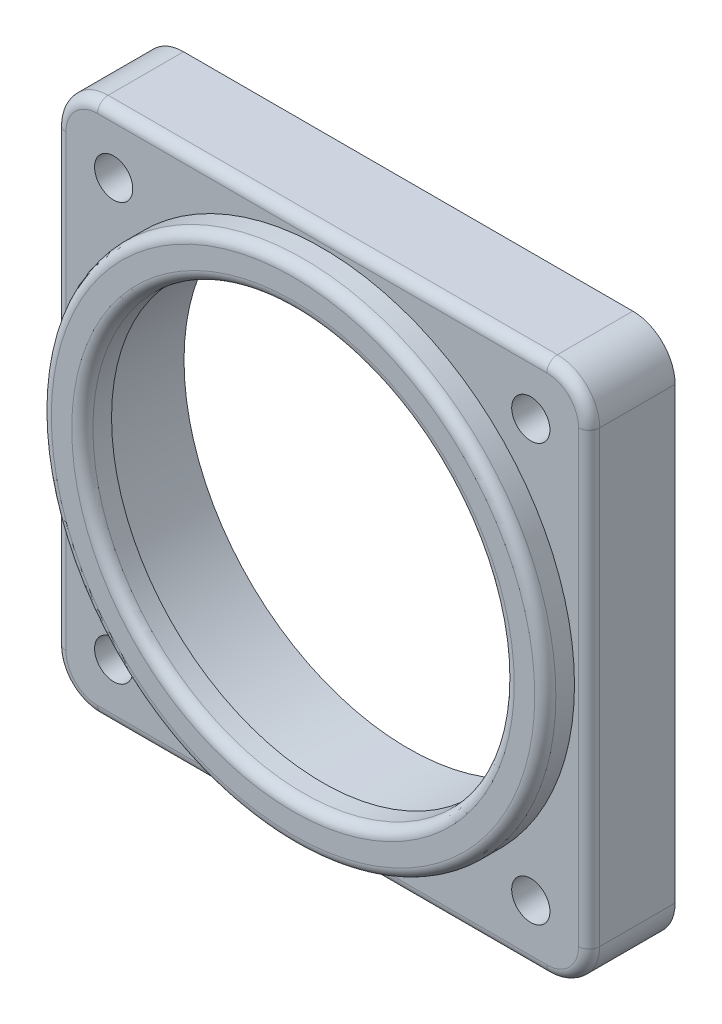
from build123d import *

# Parameters (mm, degrees)
SKETCH1_R               = 2.159
SKETCH1_R_2             = 28.5115
BOSS_EXTRUDE1_DEPTH     = 9.7155
SKETCH1_3_R             = 28.5115
SKETCH1_3_R_2           = 23.8125
EXTENDED_BEZEL_DEPTH    = 13.0175
SKETCH1_5_R             = 28.5115
SKETCH1_5_R_2           = 23.8125
BOSS_EXTRUDE4_DEPTH     = 6.35
SKETCH2_R               = 25.3365
CUT_EXTRUDE1_DEPTH      = 7.35
CUT_EXTRUDE1_DEPTH_BACK = 9.7155
FILLET1_R               = 1.1938
SKETCH3_R               = 28.5115
CUT_EXTRUDE2_DEPTH      = 7.35


with BuildPart() as part:
    # Sketch1 → Boss-Extrude1 (new body)
    with BuildSketch(Plane.XY):
        with BuildLine():
            ThreePointArc((-24.49722379, -28.024879905), (-26.788104009, -26.788104009), (-28.024879905, -24.49722379))
            Line((-28.024879905, -24.49722379), (-30.1625, -14.199031657))
            Line((-30.1625, -14.199031657), (-30.1625, 14.199031657))
            Line((-30.1625, 14.199031657), (-28.024879905, 24.49722379))
            ThreePointArc((-28.024879905, 24.49722379), (-26.788104009, 26.788104009), (-24.49722379, 28.024879905))
            Line((-24.49722379, 28.024879905), (-14.199031657, 30.1625))
            Line((-14.199031657, 30.1625), (14.199031657, 30.1625))
            Line((14.199031657, 30.1625), (24.441349319, 28.268787691))
            ThreePointArc((24.441349319, 28.268787691), (26.949748619, 26.949748619), (28.268787691, 24.441349319))
            Line((28.268787691, 24.441349319), (30.1625, 14.199031657))
            Line((30.1625, 14.199031657), (30.1625, -14.199031657))
            Line((30.1625, -14.199031657), (28.024879905, -24.49722379))
            ThreePointArc((28.024879905, -24.49722379), (26.788104009, -26.788104009), (24.49722379, -28.024879905))
            Line((24.49722379, -28.024879905), (14.199031657, -30.1625))
            Line((14.199031657, -30.1625), (-14.199031657, -30.1625))
            Line((-14.199031657, -30.1625), (-24.49722379, -28.024879905))
        make_face()
        with Locations((-23.573172318, -23.573172318)):
            Circle(SKETCH1_R, mode=Mode.SUBTRACT)
        with Locations((23.573172318, -23.573172318)):
            Circle(SKETCH1_R, mode=Mode.SUBTRACT)
        with Locations((23.573172318, 23.573172318)):
            Circle(SKETCH1_R, mode=Mode.SUBTRACT)
        with Locations((-23.573172318, 23.573172318)):
            Circle(SKETCH1_R, mode=Mode.SUBTRACT)
        Circle(SKETCH1_R_2, mode=Mode.SUBTRACT)
        with BuildLine():
            Line((28.268787691, 24.441349319), (30.1625, 14.199031657))
            Line((30.1625, 14.199031657), (30.1625, 25.3873))
            ThreePointArc((30.1625, 25.3873), (28.763876302, 28.763876302), (25.3873, 30.1625))
            Line((25.3873, 30.1625), (14.199031657, 30.1625))
            Line((14.199031657, 30.1625), (24.441349319, 28.268787691))
            ThreePointArc((24.441349319, 28.268787691), (26.949748619, 26.949748619), (28.268787691, 24.441349319))
        make_face()
        with BuildLine():
            Line((-30.1625, 25.3873), (-30.1625, 14.199031657))
            Line((-30.1625, 14.199031657), (-28.024879905, 24.49722379))
            ThreePointArc((-28.024879905, 24.49722379), (-26.788104009, 26.788104009), (-24.49722379, 28.024879905))
            Line((-24.49722379, 28.024879905), (-14.199031657, 30.1625))
            Line((-14.199031657, 30.1625), (-25.3873, 30.1625))
            ThreePointArc((-25.3873, 30.1625), (-28.763876302, 28.763876302), (-30.1625, 25.3873))
        make_face()
        with BuildLine():
            Line((-25.3873, -30.1625), (-14.199031657, -30.1625))
            Line((-14.199031657, -30.1625), (-24.49722379, -28.024879905))
            ThreePointArc((-24.49722379, -28.024879905), (-26.788104009, -26.788104009), (-28.024879905, -24.49722379))
            Line((-28.024879905, -24.49722379), (-30.1625, -14.199031657))
            Line((-30.1625, -14.199031657), (-30.1625, -25.3873))
            ThreePointArc((-30.1625, -25.3873), (-28.763876302, -28.763876302), (-25.3873, -30.1625))
        make_face()
        with BuildLine():
            Line((24.49722379, -28.024879905), (14.199031657, -30.1625))
            Line((14.199031657, -30.1625), (25.3873, -30.1625))
            ThreePointArc((25.3873, -30.1625), (28.763876302, -28.763876302), (30.1625, -25.3873))
            Line((30.1625, -25.3873), (30.1625, -14.199031657))
            Line((30.1625, -14.199031657), (28.024879905, -24.49722379))
            ThreePointArc((28.024879905, -24.49722379), (26.788104009, -26.788104009), (24.49722379, -28.024879905))
        make_face()
    extrude(amount=BOSS_EXTRUDE1_DEPTH)

    # Sketch1_3 → Extended Bezel (add)
    with BuildSketch(Plane.XY):
        Circle(SKETCH1_3_R)
        Circle(SKETCH1_3_R_2, mode=Mode.SUBTRACT)
    extrude(amount=EXTENDED_BEZEL_DEPTH)

    # Sketch1_5 → Boss-Extrude4 (add)
    with BuildSketch(Plane.XY):
        Circle(SKETCH1_5_R)
        Circle(SKETCH1_5_R_2, mode=Mode.SUBTRACT)
    extrude(amount=-BOSS_EXTRUDE4_DEPTH)

    # Sketch2 → Cut-Extrude1 (cut, two sides)
    with BuildSketch(Plane(origin=(0, 0, 0), x_dir=(-1, 0, 0), z_dir=(0, 0, -1))) as cut_extrude1_sk:
        Circle(SKETCH2_R)
    extrude(amount=CUT_EXTRUDE1_DEPTH, mode=Mode.SUBTRACT)
    extrude(cut_extrude1_sk.sketch, amount=-CUT_EXTRUDE1_DEPTH_BACK, mode=Mode.SUBTRACT)

    # Fillet1
    fillet1_edges = [part.edges().sort_by_distance(p)[0] for p in [
        (28.763876302, -28.763876302, 9.7155),
        (30.1625, 0, 9.7155),
        (28.763876302, 28.763876302, 9.7155),
        (0, 30.1625, 9.7155),
        (-28.763876302, 28.763876302, 9.7155),
        (-30.1625, 0, 9.7155),
        (-23.8125, 0, 13.0175),
        (-28.5115, 0, 13.0175),
        (-28.763876302, -28.763876302, 9.7155),
        (0, -30.1625, 9.7155),
    ]]
    fillet(fillet1_edges, radius=FILLET1_R)

    # Sketch3 → Cut-Extrude2 (cut, through all)
    with BuildSketch(Plane(origin=(0, 0, 0), x_dir=(-1, 0, 0), z_dir=(0, 0, -1))):
        Circle(SKETCH3_R)
    extrude(amount=CUT_EXTRUDE2_DEPTH, mode=Mode.SUBTRACT)


solid = part.part
